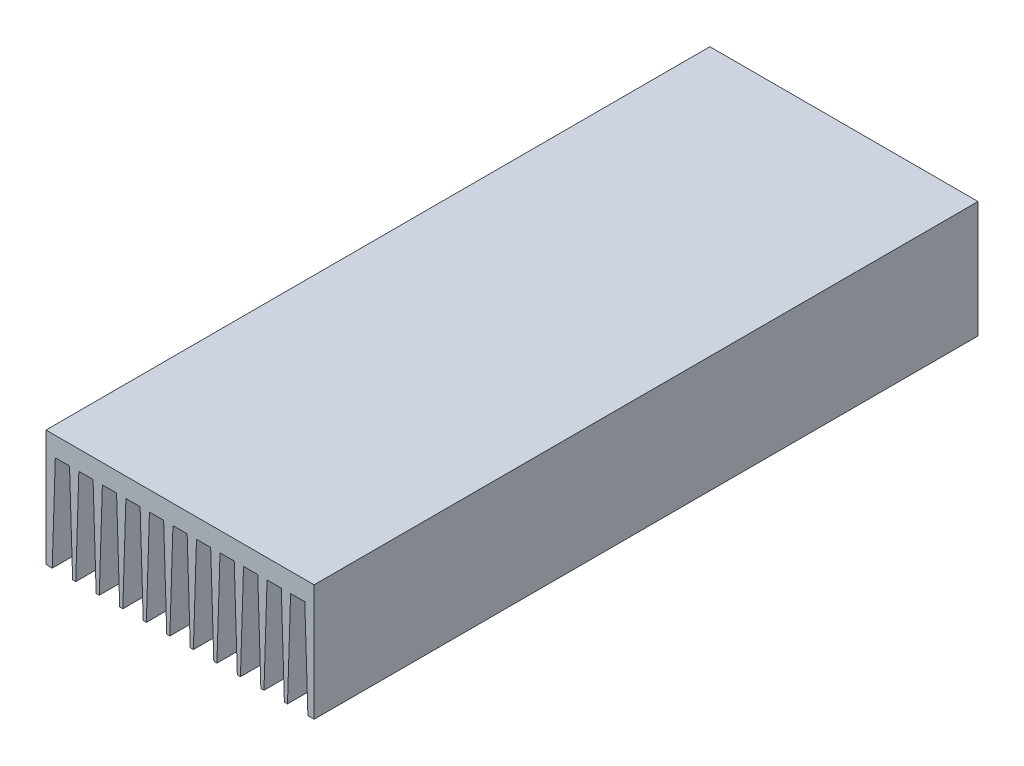
from build123d import *

# Parameters (mm, degrees)
RESSALTO_EXTRUS_O1_DEPTH = 285


with BuildPart() as part:
    # Esboço1 → Ressalto-extrusão1 (new body)
    with BuildSketch(Plane.XY):
        Polygon((0.117023133, 0.000822983), (0.117023133, 50.000822983), (115.217023133, 50.000822983), (115.217023133, 0.000822983), (112.54742137, 0.000822983), (111.217023133, 41.700822983), (105.117023133, 41.700822983), (103.787625897, 0.000822983), (102.44742137, 0.000822983), (101.117023133, 41.700822983), (95.017023133, 41.700822983), (93.687625897, 0.000822983), (92.34742137, 0.000822983), (91.017023133, 41.700822983), (84.917023133, 41.700822983), (83.587625897, 0.000822983), (82.24742137, 0.000822983), (80.917023133, 41.700822983), (74.817023133, 41.700822983), (73.487625897, 0.000822983), (72.14742137, 0.000822983), (70.817023133, 41.700822983), (64.717023133, 41.700822983), (63.387625897, 0.000822983), (62.04742137, 0.000822983), (60.717023133, 41.700822983), (54.617023133, 41.700822983), (53.287625897, 0.000822983), (51.94742137, 0.000822983), (50.617023133, 41.700822983), (44.517023133, 41.700822983), (43.187625897, 0.000822983), (41.84742137, 0.000822983), (40.517023133, 41.700822983), (34.417023133, 41.700822983), (33.087625897, 0.000822983), (31.74742137, 0.000822983), (30.417023133, 41.700822983), (24.317023133, 41.700822983), (22.987625897, 0.000822983), (21.64742137, 0.000822983), (20.317023133, 41.700822983), (14.217023133, 41.700822983), (12.887625897, 0.000822983), (11.54742137, 0.000822983), (10.217023133, 41.700822983), (4.117023133, 41.700822983), (2.78630177, -0.040711704), align=None)
    extrude(amount=RESSALTO_EXTRUS_O1_DEPTH)


solid = part.part
